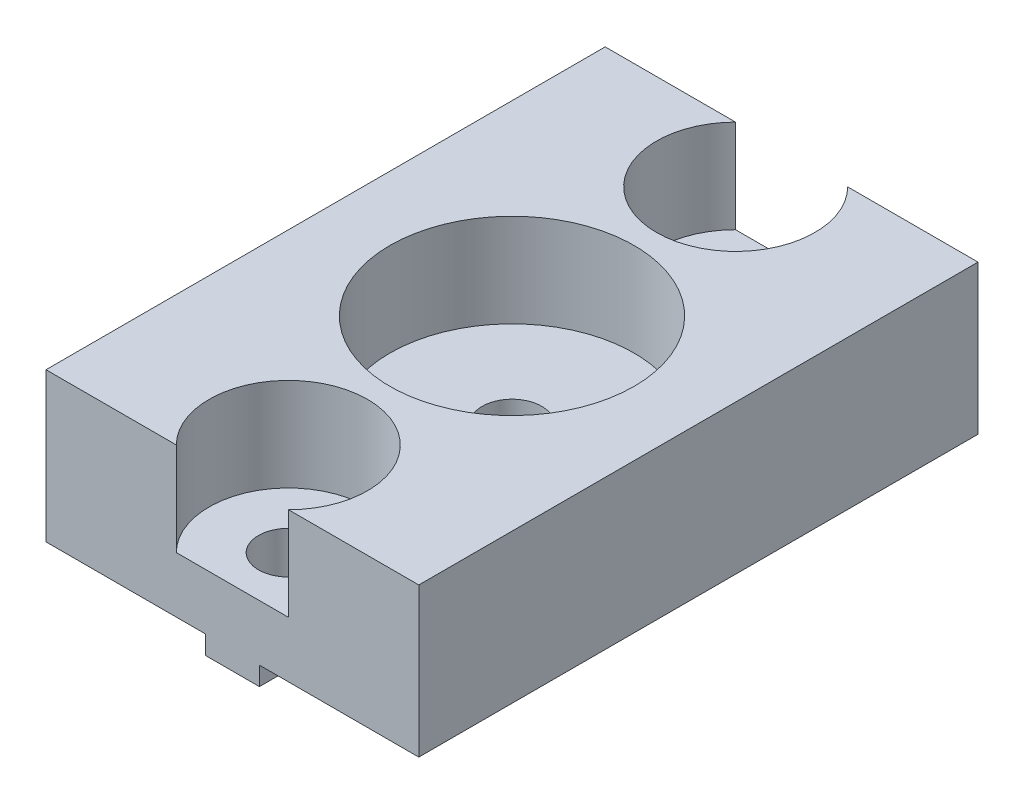
from build123d import *

# Parameters (mm, degrees)
MAIN_DEPTH        = 15
SKETCH5_R         = 1.6
FIXHOLE_DEPTH     = 10
SKETCH3_R         = 6.55
SKETCH3_R_2       = 4.25
BEARINGHOLE_DEPTH = 5


with BuildPart() as part:
    # Sketch1 → Main (new body, symmetric)
    with BuildSketch(Plane.XY):
        Polygon((-10, 9), (10, 9), (10, 1), (1.45, 1), (1.45, 0), (-1.45, 0), (-1.45, 1), (-10, 1), align=None)
    extrude(amount=MAIN_DEPTH, both=True)

    # Sketch5 → FixHole (cut, through all)
    with BuildSketch(Plane(origin=(0, 0, 0), x_dir=(-1, 0, 0), z_dir=(0, -1, 0))):
        with Locations((0, 12)):
            Circle(SKETCH5_R)
        with Locations((0, -12)):
            Circle(SKETCH5_R)
        Circle(SKETCH5_R)
    extrude(amount=-FIXHOLE_DEPTH, mode=Mode.SUBTRACT)

    # Sketch3 → BearingHole (cut)
    with BuildSketch(Plane(origin=(0, 9, 0), x_dir=(1, 0, 0), z_dir=(0, 1, 0))):
        Circle(SKETCH3_R)
        with Locations((0, 12)):
            Circle(SKETCH3_R_2)
        with Locations((0, -12)):
            Circle(SKETCH3_R_2)
    extrude(amount=-BEARINGHOLE_DEPTH, mode=Mode.SUBTRACT)


solid = part.part
